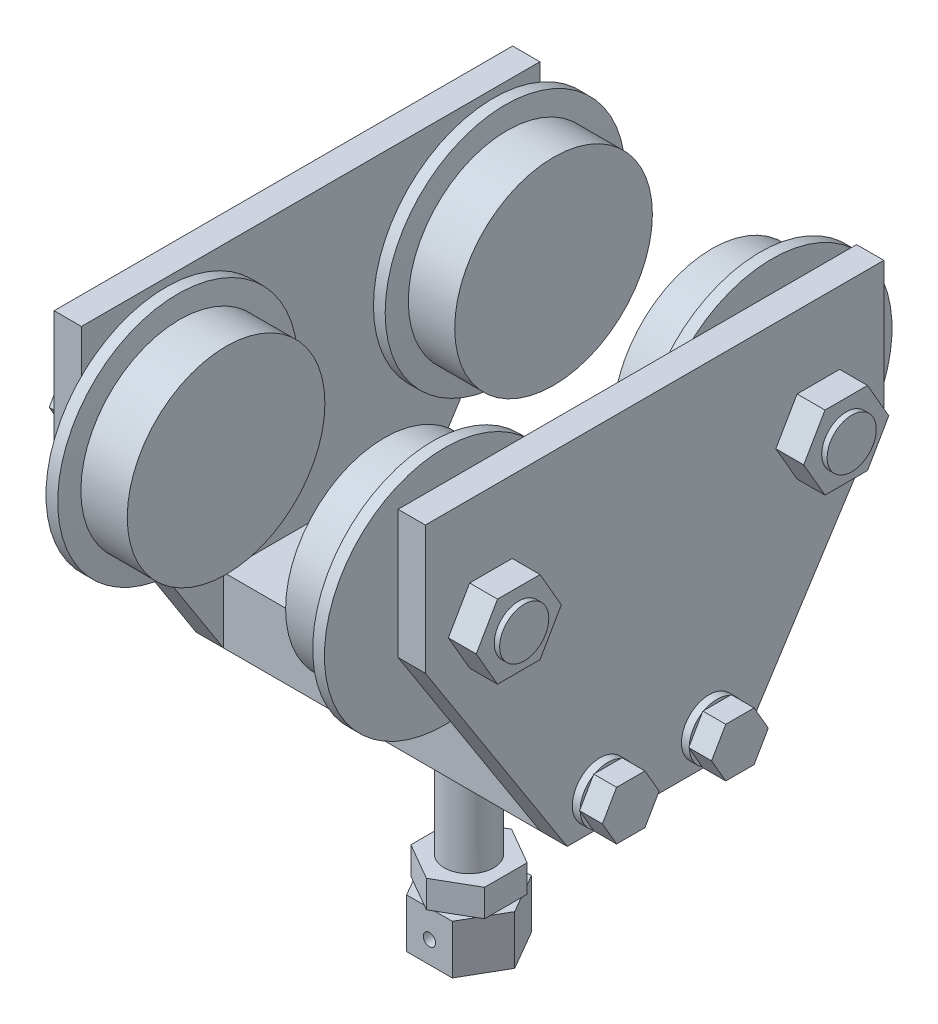
from build123d import *

# Parameters (mm, degrees)
YOKE_CROSS_SECTION_W           = 101.6
YOKE_CROSS_SECTION_H           = 38.1
YOKE_DEPTH                     = 92.101483
SIDEPLATE_DEPTH                = 15.875
WHEEL_PIN_NUT_DEPTH            = 16.2306
WHEEL_PIN_PROJECTION_PROFILE_R = 14.2875
WHEEL_PIN_PROJECTION_DEPTH     = 3.175
LOCKNUTS_PROFILE_R             = 16.129
LOCKNUTS_DEPTH                 = 4.572
SCREWS_DEPTH                   = 13.3096
PROFILE_R                      = 22.225
KING_BOLT_HEAD_DEPTH           = 25.4
DIA_R                          = 14.2875
KING_BOLT_DEPTH                = 83.052101
KING_BOLT_JAM_NUT_DEPTH        = 15.875
KING_BOLT_NUT_DEPTH            = 28.575
SKETCH5_R                      = 14.2875
EXTENDED_KING_BOLT_DEPTH       = 6.35
CHAMFER1_SIZE                  = 2.38125
COTTER_PIN_HOLE_REACH          = 190.119
SKETCH7_R                      = 3.571875


with BuildPart() as part:
    # YOKE CROSS SECTION → YOKE (new body)
    with BuildSketch(Plane(origin=(0, 0, 0), x_dir=(0, 0, -1), z_dir=(1, 0, 0))):
        with Locations((0, 19.05)):
            Rectangle(YOKE_CROSS_SECTION_W, YOKE_CROSS_SECTION_H)
    extrude(amount=YOKE_DEPTH)

    # SIDEPLATE PROFILE → SIDEPLATE (add)
    with BuildSketch(Plane(origin=(92.101482525, 0, 0), x_dir=(0, 0, -1), z_dir=(1, 0, 0))):
        Polygon((0, 0), (50.8, 0), (133.35, 128.517771554), (133.35, 203.2), (-133.35, 203.2), (-133.35, 128.517771554), (-50.8, 0), align=None)
    extrude(amount=SIDEPLATE_DEPTH)

    # WHEEL PIN NUT PROFILE → WHEEL PIN NUT (add)
    with BuildSketch(Plane(origin=(107.976482525, 0, 0), x_dir=(0, 0, -1), z_dir=(1, 0, 0))):
        Polygon((-70.503324087, 139.7), (-82.876662043, 161.13125), (-107.623337957, 161.13125), (-119.996675913, 139.7), (-107.623337957, 118.26875), (-82.876662043, 118.26875), align=None)
    wheel_pin_nut = extrude(amount=WHEEL_PIN_NUT_DEPTH)

    # WHEEL PIN PROJECTION PROFILE → WHEEL PIN PROJECTION (add)
    with BuildSketch(Plane(origin=(124.207082525, 0, 0), x_dir=(0, 0, -1), z_dir=(1, 0, 0))):
        with Locations((-95.25, 139.7)):
            Circle(WHEEL_PIN_PROJECTION_PROFILE_R)
    wheel_pin_projection = extrude(amount=WHEEL_PIN_PROJECTION_DEPTH)

    # LOCKNUTS PROFILE → LOCKNUTS (add)
    with BuildSketch(Plane(origin=(107.976482525, 0, 0), x_dir=(0, 0, -1), z_dir=(1, 0, 0))):
        with Locations(Location((-31.75, 19.05, 0), (0, 0, 180))):  # turned: the seam where the file's is
            Circle(LOCKNUTS_PROFILE_R)
    locknuts = extrude(amount=LOCKNUTS_DEPTH)

    # SCREWS PROFILE → SCREWS (add)
    with BuildSketch(Plane(origin=(112.548482525, 0, 0), x_dir=(0, 0, -1), z_dir=(1, 0, 0))):
        Polygon((-15.252216058, 19.05), (-23.501108029, 33.3375), (-39.998891971, 33.3375), (-48.247783942, 19.05), (-39.998891971, 4.7625), (-23.501108029, 4.7625), align=None)
    screws = extrude(amount=SCREWS_DEPTH)

    # PROFILE → KING BOLT HEAD (add)
    with BuildSketch(Plane(origin=(0, 38.1, 0), x_dir=(-1, 0, 0), z_dir=(0, 1, 0))):
        with Locations(Location((0, 0, 0), (0, 0, 90))):  # turned: the seam where the file's is
            Circle(PROFILE_R)
    extrude(amount=KING_BOLT_HEAD_DEPTH)

    # Mirror1: WHEEL PIN NUT, WHEEL PIN PROJECTION across plane
    add(wheel_pin_nut.mirror(Plane.XY))
    add(wheel_pin_projection.mirror(Plane.XY))

    # Mirror YOKE SCREWS: LOCKNUTS, SCREWS across plane
    add(locknuts.mirror(Plane.XY))
    add(screws.mirror(Plane.XY))

    # Mirror SIDE 1: part across plane


with BuildPart() as part_1:
    add(part.part)
    add(part.part.mirror(Plane(origin=(0, 0, 0), x_dir=(0, 0, 1), z_dir=(1, 0, 0))))

    # DIA. → KING BOLT (add)
    with BuildSketch(Plane.XZ):
        with Locations(Location((0, 0, 0), (0, 0, 90))):  # turned: the seam where the file's is
            Circle(DIA_R)
    extrude(amount=KING_BOLT_DEPTH)

    # KING BOLT JAN NUT PROFILE → KING BOLT JAM NUT (add)
    with BuildSketch(Plane.XZ.offset(83.052100888)):
        Polygon((0, -24.754008262), (21.4376, -12.377004131), (21.4376, 12.377004131), (0, 24.754008262), (-21.4376, 12.377004131), (-21.4376, -12.377004131), align=None)
    extrude(amount=KING_BOLT_JAM_NUT_DEPTH)

    # KING BOLT NUT PROFILE → KING BOLT NUT (add)
    with BuildSketch(Plane.XZ.offset(98.927100888)):
        Polygon((26.579763018, 0), (13.289881509, 23.01875), (-13.289881509, 23.01875), (-26.579763018, 0), (-13.289881509, -23.01875), (13.289881509, -23.01875), align=None)
    extrude(amount=KING_BOLT_NUT_DEPTH)

    # Sketch5 → EXTENDED KING BOLT (add)
    with BuildSketch(Plane.XZ.offset(127.502100888)):
        with Locations(Location((0, 0, 0), (0, 0, 90))):  # turned: the seam where the file's is
            Circle(SKETCH5_R)
    extrude(amount=EXTENDED_KING_BOLT_DEPTH)

    # Chamfer1
    chamfer1_edges = [part_1.edges().sort_by_distance(p)[0] for p in [
        (0, -133.852100888, -14.2875),
    ]]
    chamfer(chamfer1_edges, length=CHAMFER1_SIZE)

    # Sketch6 → WHEEL (revolve)
    with BuildSketch(Plane.XY.offset(95.25), mode=Mode.PRIVATE) as wheel_sk:
        Polygon((73.051482525, 197.195784675), (74.162588551, 209.55), (80.988982525, 209.55), (80.988982525, 158.75), (92.101482525, 158.75), (92.101482525, 139.7), (46.063982525, 139.7), (46.063982525, 197.195784675), align=None)
    wheel = revolve(wheel_sk.sketch.rotate(Axis((127.382082525, 139.7, 95.25), (-1, 0, 0)), 90), axis=Axis((127.382082525, 139.7, 95.25), (-1, 0, 0)))  # turned: the seam where the file's is

    # Mirror2: WHEEL across plane
    add(wheel.mirror(Plane.XY))

    # Mirror3: WHEEL across plane
    add(wheel.mirror(Plane(origin=(0, 0, 0), x_dir=(0, 0, 1), z_dir=(1, 0, 0))))

    # Mirror3 copy 1 sketch → Mirror3 copy 1 (revolve)
    with BuildSketch(Plane(origin=(0, 0, -95.25), x_dir=(-1, 0, 0), z_dir=(0, 0, -1))):
        Polygon((73.051482525, 197.195784675), (74.162588551, 209.55), (80.988982525, 209.55), (80.988982525, 158.75), (92.101482525, 158.75), (92.101482525, 139.7), (46.063982525, 139.7), (46.063982525, 197.195784675), align=None)
    revolve(axis=Axis((-127.382082525, 139.7, -95.25), (1, 0, 0)))

    # Sketch7 → COTTER PIN HOLE (cut, up to next)
    with BuildSketch(Plane.XY.offset(23.01875), mode=Mode.PRIVATE) as cotter_pin_hole_sk1:
        with Locations((0, -114.802100888)):
            Circle(SKETCH7_R)
    cotter_pin_hole_tool1 = extrude(cotter_pin_hole_sk1.sketch, amount=-COTTER_PIN_HOLE_REACH, mode=Mode.PRIVATE) & part_1.part
    add(cotter_pin_hole_tool1.solids().sort_by_distance((0, -114.802101, 23.01875))[0], mode=Mode.SUBTRACT)


solid = part_1.part
